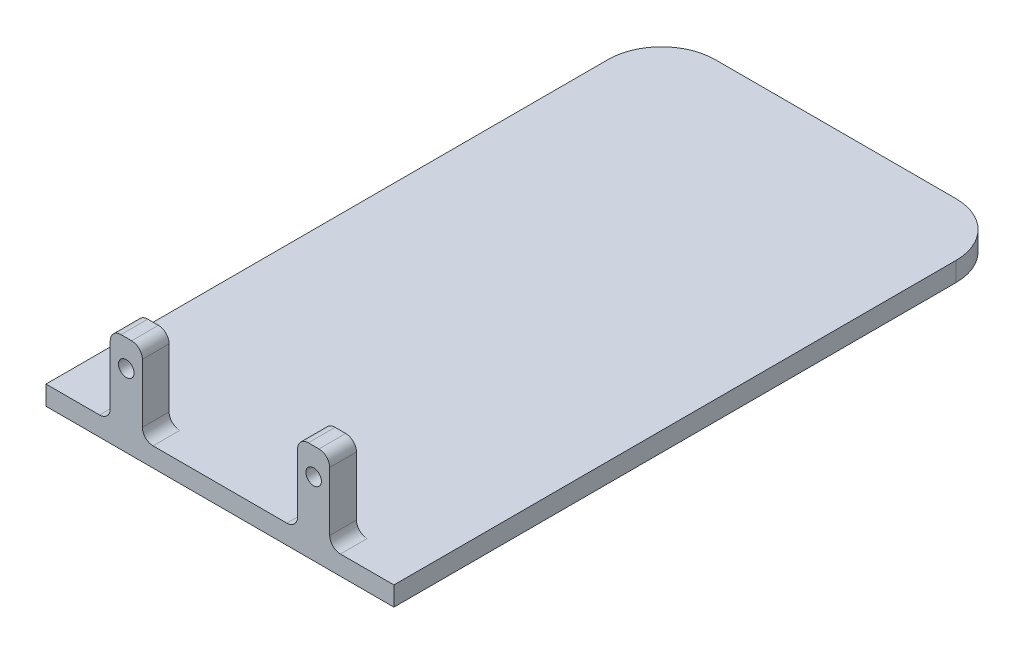
from build123d import *

# Parameters (mm, degrees)
SKETCH_1_W      = 65
SKETCH_1_H      = 115
EXTRUDE_1_DEPTH = 3.6
SKETCH_3_W      = 6
SKETCH_3_H      = 15
SKETCH_3_R      = 1.45
EXTRUDE_2_DEPTH = 5
FILLET_1_R      = 10
FILLET_2_R      = 2


with BuildPart() as part:
    # 草图1 → 凸台-拉伸1 (new body)
    with BuildSketch(Plane(origin=(0, 0, 0), x_dir=(1, 0, 0), z_dir=(0, 1, 0))):
        with Locations((-5.550310529, -31.459318732)):
            Rectangle(SKETCH_1_W, SKETCH_1_H)
    extrude(amount=EXTRUDE_1_DEPTH)

    # 草图3 → 凸台-拉伸2 (add)
    with BuildSketch(Plane.XY.offset(88.959318732)):
        with Locations((-23.050310529, 11.1)):
            Rectangle(SKETCH_3_W, SKETCH_3_H)
        with Locations((-23.050310529, 13.6)):
            Circle(SKETCH_3_R, mode=Mode.SUBTRACT)
        with Locations((11.949689471, 11.1)):
            Rectangle(SKETCH_3_W, SKETCH_3_H)
        with Locations((11.949689471, 13.6)):
            Circle(SKETCH_3_R, mode=Mode.SUBTRACT)
    extrude(amount=-EXTRUDE_2_DEPTH)

    # 圆角1
    fillet_1_edges = [part.edges().sort_by_distance(p)[0] for p in [
        (-38.050310529, 1.8, -26.040681268),
        (26.949689471, 1.8, -26.040681268),
    ]]
    fillet(fillet_1_edges, radius=FILLET_1_R)

    # 圆角2
    fillet_2_edges = [part.edges().sort_by_distance(p)[0] for p in [
        (-26.050310529, 3.6, 86.459318732),
        (-26.050310529, 18.6, 86.459318732),
        (-20.050310529, 18.6, 86.459318732),
        (-20.050310529, 3.6, 86.459318732),
        (14.949689471, 18.6, 86.459318732),
        (14.949689471, 3.6, 86.459318732),
        (8.949689471, 3.6, 86.459318732),
        (8.949689471, 18.6, 86.459318732),
    ]]
    fillet(fillet_2_edges, radius=FILLET_2_R)


solid = part.part
